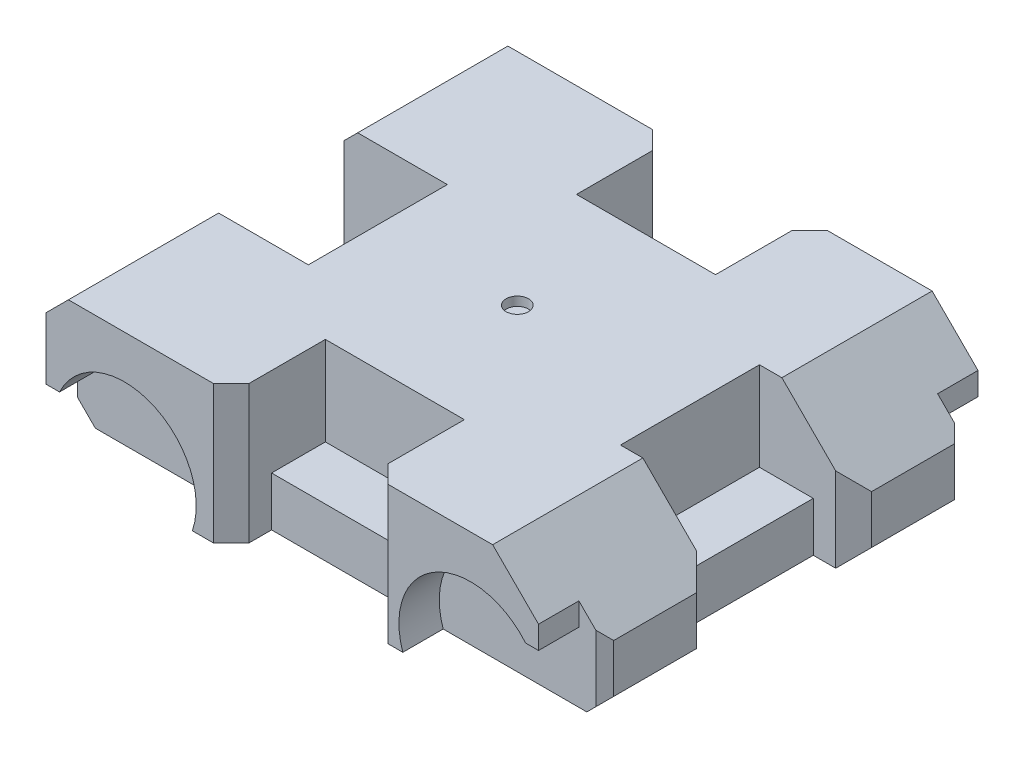
from build123d import *

# Parameters (mm, degrees)
SKETCH_1_W          = 588
SKETCH_1_H          = 490
EXTRUDE_1_DEPTH     = 154
SKETCH_2_R          = 80
CUT_EXTRUDE_1_DEPTH = 45
SKETCH_3_W          = 155
SKETCH_3_H          = 105
SKETCH_3_W_2        = 105
SKETCH_3_H_2        = 155
SKETCH_3_W_3        = 135
CUT_EXTRUDE_2_DEPTH = 99
CHAMFER_1_SIZE      = 80
SKETCH_4_W          = 45
SKETCH_4_H          = 155
SKETCH_4_W_2        = 155
SKETCH_4_H_2        = 45
SKETCH_4_W_3        = 50
CUT_EXTRUDE_3_DEPTH = 56
CHAMFER_2_SIZE      = 20
CHAMFER_3_SIZE      = 35
SKETCH_5_W          = 85
SKETCH_5_H          = 155
CUT_EXTRUDE_4_DEPTH = 47
SKETCH_6_R          = 12.5
CUT_EXTRUDE_5_DEPTH = 10
CHAMFER_4_SIZE      = 10
SKETCH_7_W          = 28.842878722
SKETCH_7_H          = 45
CUT_EXTRUDE_6_DEPTH = 155
CHAMFER_6_SIZE      = 10
CUT_EXTRUDE_7_DEPTH = 45
CUT_EXTRUDE_START   = -490
CUT_EXTRUDE_8_DEPTH = 45
SKETCH_9_W          = 45
SKETCH_9_H          = 60
CUT_EXTRUDE_9_DEPTH = 50
CHAMFER_7_SIZE      = 20


with BuildPart() as part:
    # 草图1 → 凸台-拉伸1 (new body)
    with BuildSketch(Plane(origin=(0, 0, 0), x_dir=(1, 0, 0), z_dir=(0, 1, 0))):
        Rectangle(SKETCH_1_W, SKETCH_1_H)
    extrude(amount=EXTRUDE_1_DEPTH)

    # 草图2 → 切除-拉伸1 (cut)
    with BuildSketch(Plane.XY.offset(245)):
        with Locations((-196.5, 26)):
            Circle(SKETCH_2_R)
        with Locations((189.5, 26)):
            Circle(SKETCH_2_R)
    cut_extrude_1 = extrude(amount=-CUT_EXTRUDE_1_DEPTH, mode=Mode.SUBTRACT)

    # 镜向1: 切除-拉伸1 across plane
    add(cut_extrude_1.mirror(Plane.XY), mode=Mode.SUBTRACT)

    # 草图3 → 切除-拉伸2 (cut)
    with BuildSketch(Plane(origin=(0, 154, 0), x_dir=(1, 0, 0), z_dir=(0, 1, 0))):
        with Locations((0, -192.5)):
            Rectangle(SKETCH_3_W, SKETCH_3_H)
        with Locations((241.5, 0)):
            Rectangle(SKETCH_3_W_2, SKETCH_3_H_2)
        with Locations((0, 192.5)):
            Rectangle(SKETCH_3_W, SKETCH_3_H)
        with Locations((-226.5, 0)):
            Rectangle(SKETCH_3_W_3, SKETCH_3_H_2)
    extrude(amount=-CUT_EXTRUDE_2_DEPTH, mode=Mode.SUBTRACT)

    # 倒角1
    chamfer_1_edges = [part.edges().sort_by_distance(p)[0] for p in [
        (294, 154, 161.25),
        (294, 154, -161.25),
    ]]
    chamfer(chamfer_1_edges, length=CHAMFER_1_SIZE)

    # 草图4 → 切除-拉伸3 (cut, through all)
    with BuildSketch(Plane(origin=(0, 55, 0), x_dir=(1, 0, 0), z_dir=(0, 1, 0))):
        with Locations((271.5, 0)):
            Rectangle(SKETCH_4_W, SKETCH_4_H)
        with Locations((0, 222.5)):
            Rectangle(SKETCH_4_W_2, SKETCH_4_H_2)
        with Locations((0, -222.5)):
            Rectangle(SKETCH_4_W_2, SKETCH_4_H_2)
        with Locations((-269, 0)):
            Rectangle(SKETCH_4_W_3, SKETCH_4_H)
    extrude(amount=-CUT_EXTRUDE_3_DEPTH, mode=Mode.SUBTRACT)

    # 倒角2
    chamfer_2_edges = [part.edges().sort_by_distance(p)[0] for p in [
        (294, 37, -77.5),
        (294, 37, 77.5),
        (77.5, 77, -245),
        (-77.5, 77, -245),
        (77.5, 77, 245),
        (-77.5, 77, 245),
        (-294, 77, 77.5),
        (-294, 77, -77.5),
    ]]
    chamfer(chamfer_2_edges, length=CHAMFER_2_SIZE)

    # 倒角3
    chamfer_3_edges = [part.edges().sort_by_distance(p)[0] for p in [
        (-294, 154, 171.25),
        (-294, 154, -171.25),
    ]]
    chamfer(chamfer_3_edges, length=CHAMFER_3_SIZE)

    # 草图5 → 切除-拉伸4 (cut)
    with BuildSketch(Plane(origin=(0, 55, 0), x_dir=(1, 0, 0), z_dir=(0, 1, 0))):
        with Locations((-201.5, 0)):
            Rectangle(SKETCH_5_W, SKETCH_5_H)
    extrude(amount=-CUT_EXTRUDE_4_DEPTH, mode=Mode.SUBTRACT)

    # 草图6 → 切除-拉伸5 (cut)
    with BuildSketch(Plane(origin=(0, 154, 0), x_dir=(1, 0, 0), z_dir=(0, 1, 0))):
        with Locations((-3.5, 0)):
            Circle(SKETCH_6_R)
    extrude(amount=-CUT_EXTRUDE_5_DEPTH, mode=Mode.SUBTRACT)

    # 倒角4
    chamfer_4_edges = [part.edges().sort_by_distance(p)[0] for p in [
        (-294, 59.5, 245),
        (-294, 59.5, -245),
    ]]
    chamfer(chamfer_4_edges, length=CHAMFER_4_SIZE)

    # 草图7 → 切除-拉伸6 (cut, through all)
    with BuildSketch(Plane.XZ):
        with Locations((279.578560639, 222.5)):
            Rectangle(SKETCH_7_W, SKETCH_7_H)
        with Locations((279.578560639, -222.5)):
            Rectangle(SKETCH_7_W, SKETCH_7_H)
    extrude(amount=-CUT_EXTRUDE_6_DEPTH, mode=Mode.SUBTRACT)

    # 倒角6
    chamfer_6_edges = [part.edges().sort_by_distance(p)[0] for p in [
        (294, 37, 200),
        (294, 37, -200),
    ]]
    chamfer(chamfer_6_edges, length=CHAMFER_6_SIZE)

    # 草图8 → 切除-拉伸7 (cut)
    with BuildSketch(Plane.XY.offset(245)):
        with BuildLine():
            Line((265.157121278, 77.421439361), (250.78487231, 77.421439361))
            ThreePointArc((250.78487231, 77.421439361), (259.140791184, 65.372073901), (265.157121278, 52))
            Line((265.157121278, 52), (265.157121278, 77.421439361))
        make_face()
    extrude(amount=-CUT_EXTRUDE_7_DEPTH, mode=Mode.SUBTRACT)

    # 草图8<2> → 切除-拉伸8 (cut)
    with BuildSketch(Plane.XY.offset(245).offset(CUT_EXTRUDE_START)):
        with BuildLine():
            Line((265.157121278, 77.421439361), (250.78487231, 77.421439361))
            ThreePointArc((250.78487231, 77.421439361), (259.140791184, 65.372073901), (265.157121278, 52))
            Line((265.157121278, 52), (265.157121278, 77.421439361))
        make_face()
    extrude(amount=CUT_EXTRUDE_8_DEPTH, mode=Mode.SUBTRACT)

    # 草图9 → 切除-拉伸9 (cut)
    with BuildSketch(Plane.ZY.offset(294)):
        with Locations((222.5, 30)):
            Rectangle(SKETCH_9_W, SKETCH_9_H)
        with Locations((-222.5, 30)):
            Rectangle(SKETCH_9_W, SKETCH_9_H)
    extrude(amount=-CUT_EXTRUDE_9_DEPTH, mode=Mode.SUBTRACT)

    # 倒角7
    chamfer_7_edges = [part.edges().sort_by_distance(p)[0] for p in [
        (-294, 0, -148.75),
        (-294, 0, 148.75),
        (294, 0, -143.75),
        (294, 0, 143.75),
    ]]
    chamfer(chamfer_7_edges, length=CHAMFER_7_SIZE)


solid = part.part
